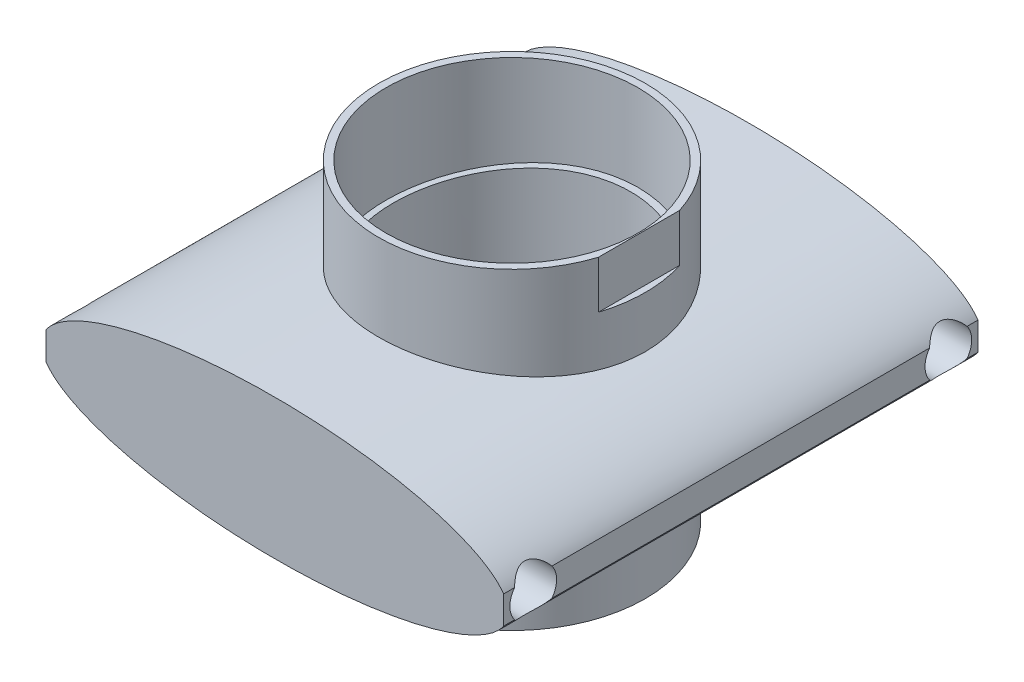
from build123d import *

# Parameters (mm, degrees)
SKETCH1_R                = 28.575
SKETCH1_R_2              = 26.9875
BOSS_EXTRUDE1_DEPTH      = 67
BOSS_EXTRUDE2_DEPTH      = 50.8
BOSS_EXTRUDE2_DEPTH_BACK = 50.8
SKETCH4_R                = 25.4
CUT_EXTRUDE1_DEPTH       = 76.2
SKETCH7_W                = 2.71552133
SKETCH7_H                = 38.476912095
CUT_EXTRUDE2_DEPTH       = 10.2
CUT_EXTRUDE5_START       = -64
SKETCH12_R               = 5
CUT_EXTRUDE5_DEPTH       = 129
SKETCH13_W               = 6.090943333
SKETCH13_H               = 19.638041435
CUT_EXTRUDE6_DEPTH       = 110


with BuildPart() as part:
    # Sketch1 → Boss-Extrude1 (new body)
    with BuildSketch(Plane(origin=(0, 0, 0), x_dir=(1, 0, 0), z_dir=(0, 1, 0))):
        Circle(SKETCH1_R)
        Circle(SKETCH1_R_2, mode=Mode.SUBTRACT)
    extrude(amount=BOSS_EXTRUDE1_DEPTH)

    # Sketch2 → Boss-Extrude2 (add, two sides: drawn at the far end of the back side and taken through both)
    with BuildSketch(Plane.XY.offset(-BOSS_EXTRUDE2_DEPTH_BACK)):
        with BuildLine():
            add(Edge.make_bspline(
                [(0, 48.5), (-50, 48.5), (-50, 33.5)],
                knots=[1.570796327, 1.570796327, 1.570796327, 3.141592654, 3.141592654, 3.141592654], degree=2, weights=[1, 0.707106781, 1]))
            add(Edge.make_bspline(
                [(-50, 33.5), (-50, 18.5), (0, 18.5)],
                knots=[3.141592654, 3.141592654, 3.141592654, 4.71238898, 4.71238898, 4.71238898], degree=2, weights=[1, 0.707106781, 1]))
            add(Edge.make_bspline(
                [(0, 18.5), (50, 18.5), (50, 33.5)],
                knots=[4.71238898, 4.71238898, 4.71238898, 6.283185307, 6.283185307, 6.283185307], degree=2, weights=[1, 0.707106781, 1]))
            add(Edge.make_bspline(
                [(50, 33.5), (50, 48.5), (0, 48.5)],
                knots=[0, 0, 0, 1.570796327, 1.570796327, 1.570796327], degree=2, weights=[1, 0.707106781, 1]))
        make_face()
    extrude(amount=BOSS_EXTRUDE2_DEPTH + BOSS_EXTRUDE2_DEPTH_BACK)

    # Sketch4 → Cut-Extrude1 (cut)
    with BuildSketch(Plane(origin=(0, 67, 0), x_dir=(1, 0, 0), z_dir=(0, 1, 0))):
        Circle(SKETCH4_R)
    extrude(amount=-CUT_EXTRUDE1_DEPTH, mode=Mode.SUBTRACT)

    # Sketch7 → Cut-Extrude2 (cut)
    with BuildSketch(Plane(origin=(0, 67, 0), x_dir=(1, 0, 0), z_dir=(0, 1, 0))):
        with Locations((28.578000506, 1.313730045)):
            Rectangle(SKETCH7_W, SKETCH7_H)
    extrude(amount=-CUT_EXTRUDE2_DEPTH, mode=Mode.SUBTRACT)

    # Sketch12 → Cut-Extrude5 (cut)
    with BuildSketch(Plane(origin=(0, 0, 0), x_dir=(0, 0, -1), z_dir=(1, 0, 0)).offset(CUT_EXTRUDE5_START)):
        with Locations((-44.45, 33.5)):
            Circle(SKETCH12_R)
    cut_extrude5 = extrude(amount=CUT_EXTRUDE5_DEPTH, mode=Mode.SUBTRACT)

    # Mirror3: Cut-Extrude5 across plane
    add(cut_extrude5.mirror(Plane.XY), mode=Mode.SUBTRACT)

    # Sketch13 → Cut-Extrude6 (cut)
    with BuildSketch(Plane.XY.offset(50.8)):
        with Locations((52.045471667, 33.920065057)):
            Rectangle(SKETCH13_W, SKETCH13_H)
        with Locations((-52.045471667, 33.920065057)):
            Rectangle(SKETCH13_W, SKETCH13_H)
    extrude(amount=-CUT_EXTRUDE6_DEPTH, mode=Mode.SUBTRACT)


solid = part.part
